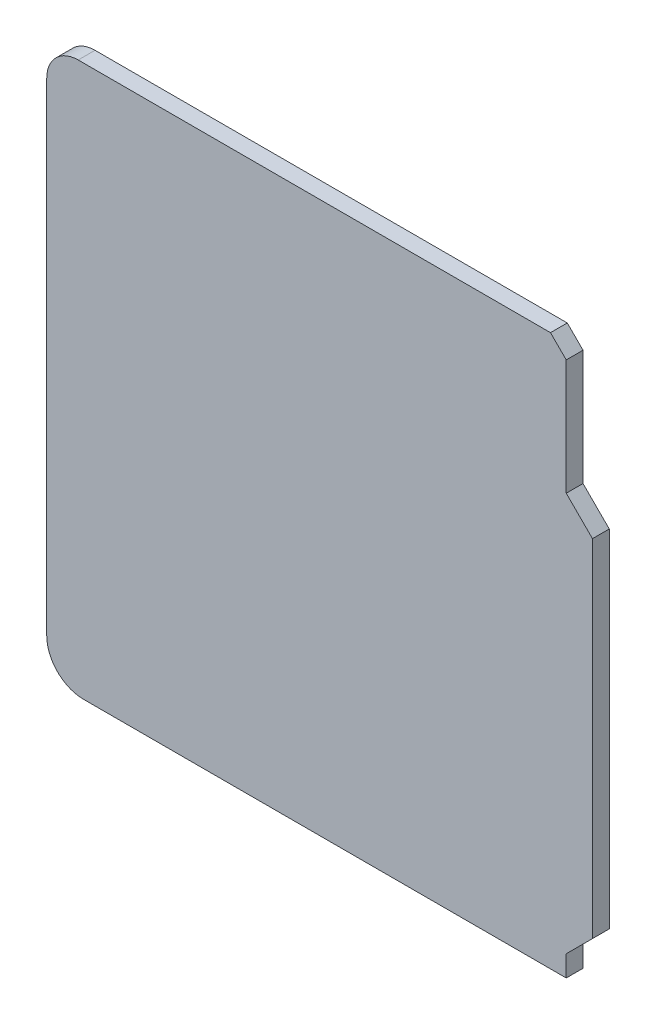
from build123d import *

# Parameters (mm, degrees)
BOSS_EXTRU_2_DEPTH = 1.6


with BuildPart() as part:
    # Esquisse2 → Boss.-Extru.2 (new body)
    with BuildSketch(Plane.XY):
        with BuildLine():
            Line((-24.709277622, 32.890166177), (20.290722378, 32.890166177))
            Line((20.290722378, 32.890166177), (21.790722378, 31.390166177))
            Line((21.790722378, 31.390166177), (21.790722378, 20.390166177))
            Line((21.790722378, 20.390166177), (24.290722378, 17.890166177))
            Line((24.290722378, 17.890166177), (24.290722378, -15.114304212))
            Line((24.290722378, -15.114304212), (21.790722378, -17.614304212))
            Line((21.790722378, -17.614304212), (21.790722378, -19.614304212))
            Line((21.790722378, -19.614304212), (-24.209277622, -19.614304212))
            ThreePointArc((-24.209277622, -19.614304212), (-26.684151356, -18.589177946), (-27.709277622, -16.114304212))
            Line((-27.709277622, -16.114304212), (-27.709277622, 29.890166177))
            ThreePointArc((-27.709277622, 29.890166177), (-26.830597966, 32.01148652), (-24.709277622, 32.890166177))
        make_face()
    extrude(amount=BOSS_EXTRU_2_DEPTH)


solid = part.part
